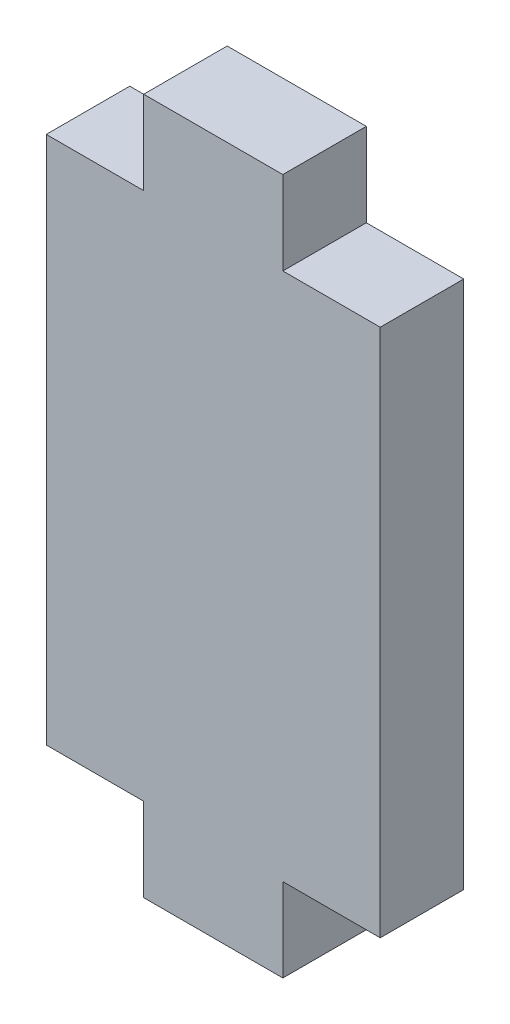
from build123d import *

# Parameters (mm, degrees)
SALIENTE_EXTRUIR1_DEPTH = 3


with BuildPart() as part:
    # Croquis1 → Saliente-Extruir1 (new body)
    with BuildSketch(Plane.XY):
        Polygon((-6, 9.5), (-2.5, 9.5), (-2.5, 12.5), (2.5, 12.5), (2.5, 9.5), (6, 9.5), (6, -9.5), (2.5, -9.5), (2.5, -12.5), (-2.5, -12.5), (-2.5, -9.5), (-6, -9.5), align=None)
    extrude(amount=SALIENTE_EXTRUIR1_DEPTH)


solid = part.part
